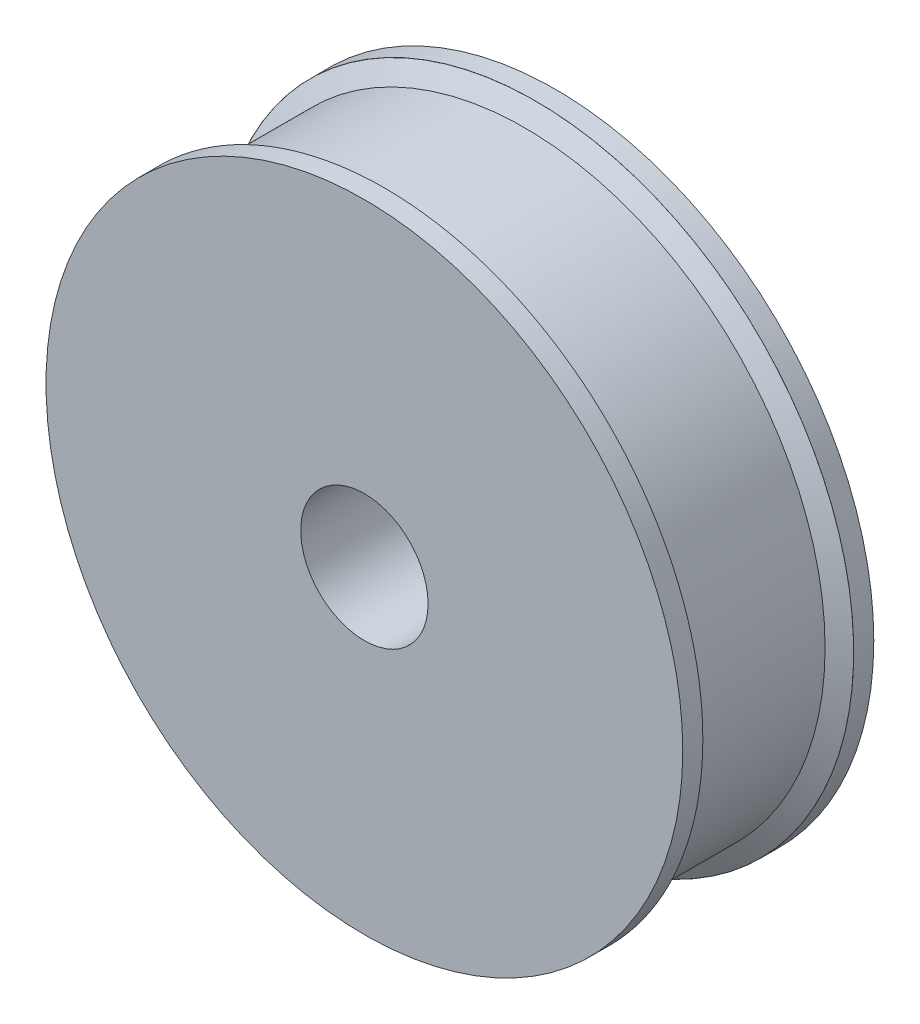
from build123d import *

# Parameters (mm, degrees)
CROQUIS1_R              = 31.75
CROQUIS1_R_2            = 6.35
SALIENTE_EXTRUIR1_DEPTH = 19.05


with BuildPart() as part:
    # Croquis1 → Saliente-Extruir1 (new body)
    with BuildSketch(Plane.XY):
        Circle(CROQUIS1_R)
        Circle(CROQUIS1_R_2, mode=Mode.SUBTRACT)
    extrude(amount=SALIENTE_EXTRUIR1_DEPTH)

    # Croquis2 → Cortar-Revolución2 (revolve, cut)
    with BuildSketch(Plane(origin=(0, 0, 0), x_dir=(0, 0, -1), z_dir=(1, 0, 0))):
        Polygon((-3.042533403, 29.934999), (-16.007466597, 29.934999), (-17.05, 31.740719823), (-17.05, 32.934999), (-2, 32.934999), (-2, 31.740719823), align=None)
    revolve(axis=Axis((0, 0, 0), (0, 0, 1)), mode=Mode.SUBTRACT)


solid = part.part
